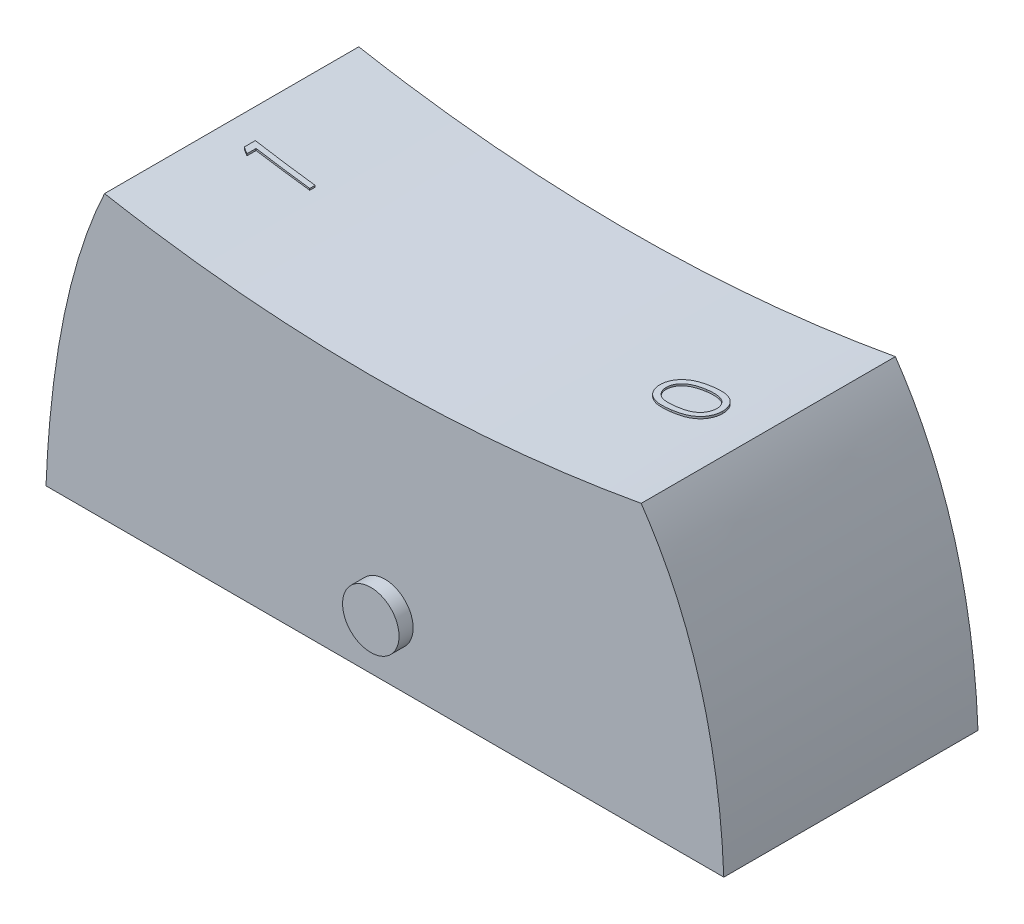
from build123d import *

# Parameters (mm, degrees)
BOSS_EXTRUDE1_DEPTH = 4.5
SKETCH2_R           = 1
BOSS_EXTRUDE2_DEPTH = 5
BOSS_EXTRUDE3_DEPTH = 5
BOSS_EXTRUDE4_DEPTH = 5
CUT_EXTRUDE1_DEPTH  = 10.5


with BuildPart() as part:
    # Sketch1 → Boss-Extrude1 (new body, symmetric)
    with BuildSketch(Plane.XY):
        with BuildLine():
            Line((-12, -5), (12, -5))
            add(Edge.make_bspline(
                [(9.073748, 5), (11.752752, 1.105643), (12, -5)],
                knots=[0, 0, 0, 1, 1, 1], degree=2))
            add(Edge.make_bspline(
                [(-9.926252, 5), (-0.426252, 3.274725), (9.073748, 5)],
                knots=[0, 0, 0, 1, 1, 1], degree=2))
            add(Edge.make_bspline(
                [(-9.926252, 5), (-11.752752, 1.105643), (-12, -5)],
                knots=[0, 0, 0, 1, 1, 1], degree=2))
        make_face()
    extrude(amount=BOSS_EXTRUDE1_DEPTH, both=True)

    # Sketch2 → Boss-Extrude2 (add, symmetric)
    with BuildSketch(Plane.XY):
        with Locations((0, -2.861144)):
            Circle(SKETCH2_R)
    extrude(amount=BOSS_EXTRUDE2_DEPTH, both=True)

    # Sketch3 → Boss-Extrude3 (add)
    with BuildSketch(Plane(origin=(0, 0, 0), x_dir=(1, 0, 0), z_dir=(0, 1, 0))):
        Polygon((-8.977715, -0.501696), (-8.977715, -0.110334), (-6.861048, -0.110334), (-6.861048, -0.300291), (-8.760621, -0.300291), (-8.760621, -0.625932), align=None)
    extrude(amount=BOSS_EXTRUDE3_DEPTH)

    # Sketch4 → Boss-Extrude4 (add)
    with BuildSketch(Plane(origin=(0, 0, 0), x_dir=(1, 0, 0), z_dir=(0, 1, 0))):
        with BuildLine():
            add(Edge.make_bspline(
                [(6.390196, -0.747527), (6.35627, -0.747328), (6.290369, -0.746943), (6.194342, -0.742656), (6.104257, -0.735535), (6.020108, -0.725776), (5.941875, -0.713899), (5.869767, -0.698045), (5.803449, -0.680016), (5.742705, -0.65912), (5.686717, -0.635541), (5.634451, -0.609878), (5.585982, -0.581115), (5.54055, -0.550883), (5.49885, -0.518005), (5.460399, -0.483186), (5.425524, -0.44573), (5.3942, -0.406), (5.366733, -0.364265), (5.34239, -0.321666), (5.32234, -0.277441), (5.305937, -0.232173), (5.292548, -0.185767), (5.283351, -0.138234), (5.277574, -0.089463), (5.277021, -0.056545), (5.276741, -0.039851)],
                knots=[0, 0, 0, 0, 0.000102, 0.000198, 0.000288, 0.000373, 0.000452, 0.000526, 0.000594, 0.000658, 0.000718, 0.000776, 0.000832, 0.000887, 0.00094, 0.000992, 0.001043, 0.001093, 0.001143, 0.001192, 0.00124, 0.001289, 0.001337, 0.001385, 0.001434, 0.001484, 0.001484, 0.001484, 0.001484], degree=3))
            add(Edge.make_bspline(
                [(5.276741, -0.039851), (5.276974, -0.023009), (5.277439, 0.0105), (5.283981, 0.059864), (5.292424, 0.108368), (5.305967, 0.155276), (5.322172, 0.201476), (5.343554, 0.245818), (5.366809, 0.289867), (5.395178, 0.331623), (5.426531, 0.372334), (5.462124, 0.410496), (5.500972, 0.447085), (5.543943, 0.480718), (5.590377, 0.512839), (5.640663, 0.542226), (5.69469, 0.569491), (5.752207, 0.595148), (5.814752, 0.617583), (5.881933, 0.637531), (5.954359, 0.653881), (6.031627, 0.667402), (6.11412, 0.677897), (6.201669, 0.685535), (6.294331, 0.689571), (6.357684, 0.690331), (6.390196, 0.690721)],
                knots=[0, 0, 0, 0, 5e-05, 0.0001, 0.000149, 0.000198, 0.000247, 0.000296, 0.000346, 0.000396, 0.000447, 0.0005, 0.000552, 0.000607, 0.000663, 0.000722, 0.000782, 0.000845, 0.00091, 0.000981, 0.001055, 0.001133, 0.001216, 0.001304, 0.001397, 0.001494, 0.001494, 0.001494, 0.001494], degree=3))
            add(Edge.make_bspline(
                [(6.390196, 0.690721), (6.422564, 0.690322), (6.485775, 0.689544), (6.578024, 0.685622), (6.665102, 0.67771), (6.747101, 0.667959), (6.82406, 0.654286), (6.895928, 0.637812), (6.96296, 0.619043), (7.024675, 0.596262), (7.082093, 0.571203), (7.135722, 0.543967), (7.185995, 0.514746), (7.232551, 0.483107), (7.27535, 0.44892), (7.314331, 0.412357), (7.350151, 0.373862), (7.381849, 0.332914), (7.410434, 0.290769), (7.434533, 0.246715), (7.455413, 0.201879), (7.472484, 0.155815), (7.485724, 0.108593), (7.494825, 0.060056), (7.501222, 0.010493), (7.501709, -0.023012), (7.501954, -0.039851)],
                knots=[0, 0, 0, 0, 9.7e-05, 0.00019, 0.000277, 0.000359, 0.000437, 0.000511, 0.000581, 0.000646, 0.000708, 0.000768, 0.000826, 0.000883, 0.000937, 0.00099, 0.001043, 0.001095, 0.001146, 0.001196, 0.001245, 0.001294, 0.001343, 0.001392, 0.001442, 0.001492, 0.001492, 0.001492, 0.001492], degree=3))
            add(Edge.make_bspline(
                [(7.501954, -0.039851), (7.501672, -0.056545), (7.501116, -0.089462), (7.495363, -0.138238), (7.486112, -0.18558), (7.473161, -0.231723), (7.457307, -0.276902), (7.436652, -0.320503), (7.412864, -0.363011), (7.385774, -0.404311), (7.354735, -0.443626), (7.32041, -0.481187), (7.281919, -0.516015), (7.239866, -0.548607), (7.194366, -0.579159), (7.145389, -0.607674), (7.092852, -0.633875), (7.036421, -0.657856), (6.975247, -0.679118), (6.90876, -0.697826), (6.836285, -0.712768), (6.758191, -0.725433), (6.674318, -0.735582), (6.584636, -0.742653), (6.489316, -0.74694), (6.423838, -0.747328), (6.390196, -0.747527)],
                knots=[0, 0, 0, 0, 5e-05, 9.9e-05, 0.000147, 0.000195, 0.000242, 0.000291, 0.000339, 0.000388, 0.000439, 0.000489, 0.000541, 0.000594, 0.000649, 0.000705, 0.000764, 0.000825, 0.000889, 0.000958, 0.001032, 0.001111, 0.001195, 0.001285, 0.001381, 0.001482, 0.001482, 0.001482, 0.001482], degree=3))
        make_face()
        with BuildLine():
            add(Edge.make_bspline(
                [(6.389347, -0.55757), (6.417619, -0.557496), (6.472489, -0.557352), (6.552083, -0.553718), (6.626446, -0.548659), (6.695547, -0.542295), (6.759146, -0.532763), (6.817507, -0.521949), (6.870522, -0.508978), (6.918654, -0.493555), (6.962584, -0.475987), (7.003485, -0.456839), (7.041839, -0.436087), (7.077555, -0.413305), (7.110196, -0.388043), (7.140589, -0.361471), (7.167677, -0.332393), (7.20017, -0.292176), (7.233745, -0.239079), (7.262983, -0.17218), (7.281357, -0.103438), (7.283694, -0.05678), (7.28486, -0.033491)],
                knots=[0, 0, 0, 0, 8.5e-05, 0.000165, 0.000239, 0.000308, 0.000373, 0.000432, 0.000486, 0.000536, 0.000583, 0.000628, 0.000672, 0.000714, 0.000755, 0.000795, 0.000835, 0.000874, 0.00095, 0.001023, 0.001093, 0.001162, 0.001162, 0.001162, 0.001162], degree=3))
            add(Edge.make_bspline(
                [(7.28486, -0.033491), (7.283839, -0.010068), (7.2818, 0.036696), (7.264006, 0.105375), (7.235078, 0.171498), (7.202029, 0.223681), (7.170354, 0.263271), (7.143378, 0.291647), (7.113165, 0.317688), (7.080569, 0.342388), (7.044965, 0.365042), (7.006525, 0.385642), (6.965142, 0.40444), (6.936253, 0.41515), (6.921482, 0.420626)],
                knots=[0, 0, 0, 0, 7e-05, 0.00014, 0.000211, 0.000286, 0.000325, 0.000363, 0.000403, 0.000444, 0.000486, 0.00053, 0.000575, 0.000622, 0.000622, 0.000622, 0.000622], degree=3))
            add(Edge.make_bspline(
                [(6.921482, 0.420626), (6.902596, 0.427007), (6.864248, 0.439964), (6.804761, 0.456662), (6.742348, 0.469813), (6.677382, 0.481644), (6.609382, 0.48972), (6.538561, 0.496219), (6.464864, 0.500048), (6.414792, 0.500523), (6.389347, 0.500764)],
                knots=[0, 0, 0, 0, 6e-05, 0.000121, 0.000185, 0.000251, 0.000319, 0.000391, 0.000464, 0.000541, 0.000541, 0.000541, 0.000541], degree=3))
            add(Edge.make_bspline(
                [(6.389347, 0.500764), (6.363907, 0.500431), (6.314139, 0.49978), (6.241254, 0.497292), (6.172028, 0.490867), (6.106163, 0.483732), (6.044024, 0.473211), (5.98509, 0.461867), (5.930091, 0.446626), (5.878166, 0.430346), (5.829906, 0.411713), (5.785085, 0.391201), (5.743484, 0.369298), (5.705232, 0.345497), (5.670105, 0.320129), (5.638913, 0.292286), (5.610138, 0.263734), (5.57788, 0.223128), (5.544729, 0.1704), (5.515051, 0.104335), (5.497487, 0.035961), (5.495051, -0.010357), (5.493835, -0.033491)],
                knots=[0, 0, 0, 0, 7.6e-05, 0.000149, 0.000219, 0.000285, 0.000348, 0.000408, 0.000465, 0.000519, 0.000571, 0.00062, 0.000667, 0.000712, 0.000755, 0.000797, 0.000837, 0.000876, 0.000952, 0.001023, 0.001093, 0.001162, 0.001162, 0.001162, 0.001162], degree=3))
            add(Edge.make_bspline(
                [(5.493835, -0.033491), (5.495054, -0.056905), (5.497496, -0.103776), (5.51497, -0.172881), (5.544642, -0.239391), (5.577816, -0.292294), (5.610015, -0.332407), (5.63742, -0.360872), (5.667087, -0.387812), (5.700017, -0.41242), (5.735607, -0.435067), (5.773466, -0.456621), (5.814442, -0.475513), (5.858338, -0.493137), (5.906473, -0.508586), (5.95968, -0.521408), (6.01818, -0.533082), (6.082243, -0.541489), (6.15136, -0.548892), (6.225912, -0.553662), (6.30578, -0.557369), (6.360934, -0.557501), (6.389347, -0.55757)],
                knots=[0, 0, 0, 0, 7e-05, 0.000141, 0.000212, 0.000288, 0.000327, 0.000366, 0.000406, 0.000447, 0.00049, 0.000533, 0.000578, 0.000625, 0.000675, 0.000729, 0.000789, 0.000854, 0.000923, 0.000997, 0.001078, 0.001163, 0.001163, 0.001163, 0.001163], degree=3))
        make_face(mode=Mode.SUBTRACT)
    extrude(amount=BOSS_EXTRUDE4_DEPTH)

    # Sketch5 → Cut-Extrude1 (cut, through all)
    with BuildSketch(Plane.XY.offset(4.5)):
        with BuildLine():
            Line((-9.904127, 5.068354), (-7.757408, 6.07331))
            Line((-7.757408, 6.07331), (7.661213, 5.815335))
            Line((7.661213, 5.815335), (9.041222, 5.079014))
            add(Edge.make_bspline(
                [(-9.904127, 5.068354), (-0.422911, 3.293912), (9.041222, 5.079014)],
                knots=[0, 0, 0, 1, 1, 1], degree=2))
        make_face()
    extrude(amount=-CUT_EXTRUDE1_DEPTH, mode=Mode.SUBTRACT)


solid = part.part
